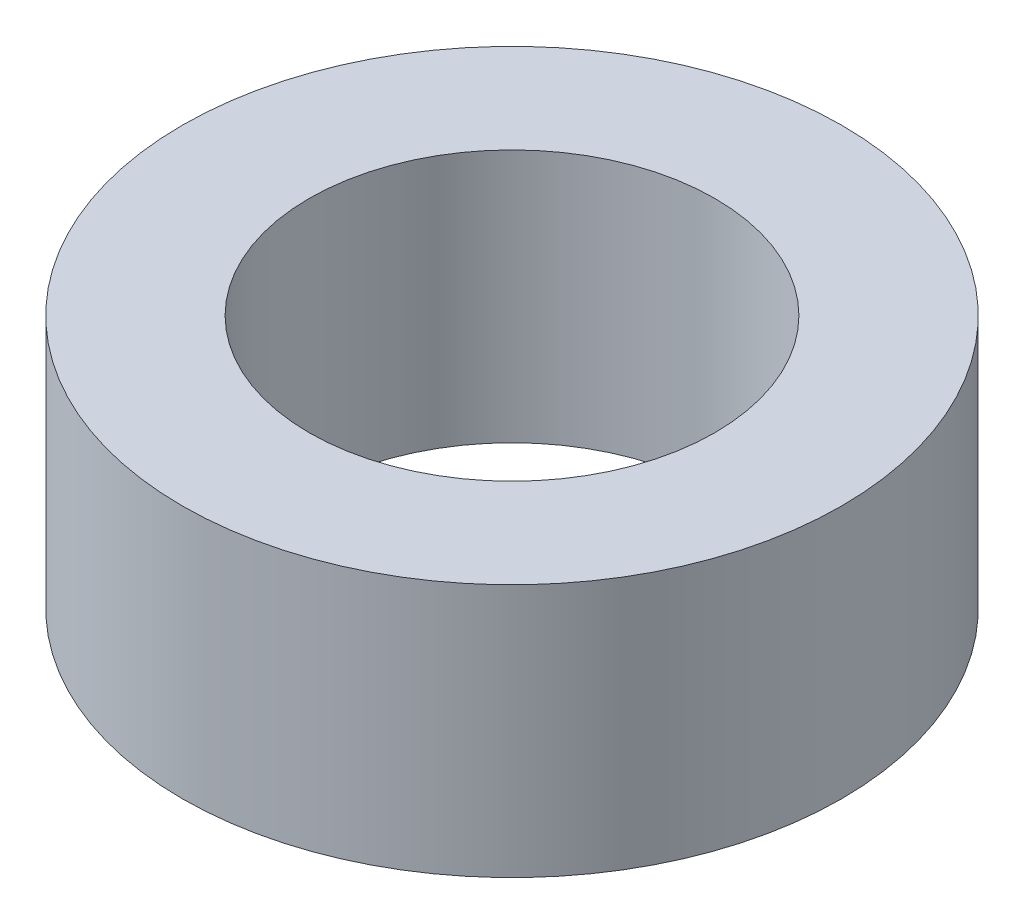
from build123d import *

# Parameters (mm, degrees)
SKETCH2_R           = 5.2
SKETCH2_R_2         = 3.2
BOSS_EXTRUDE1_DEPTH = 4


with BuildPart() as part:
    # Sketch2 → Boss-Extrude1 (new body)
    with BuildSketch(Plane(origin=(0, 0, 0), x_dir=(1, 0, 0), z_dir=(0, 1, 0))):
        Circle(SKETCH2_R)
        Circle(SKETCH2_R_2, mode=Mode.SUBTRACT)
    extrude(amount=BOSS_EXTRUDE1_DEPTH)


solid = part.part
